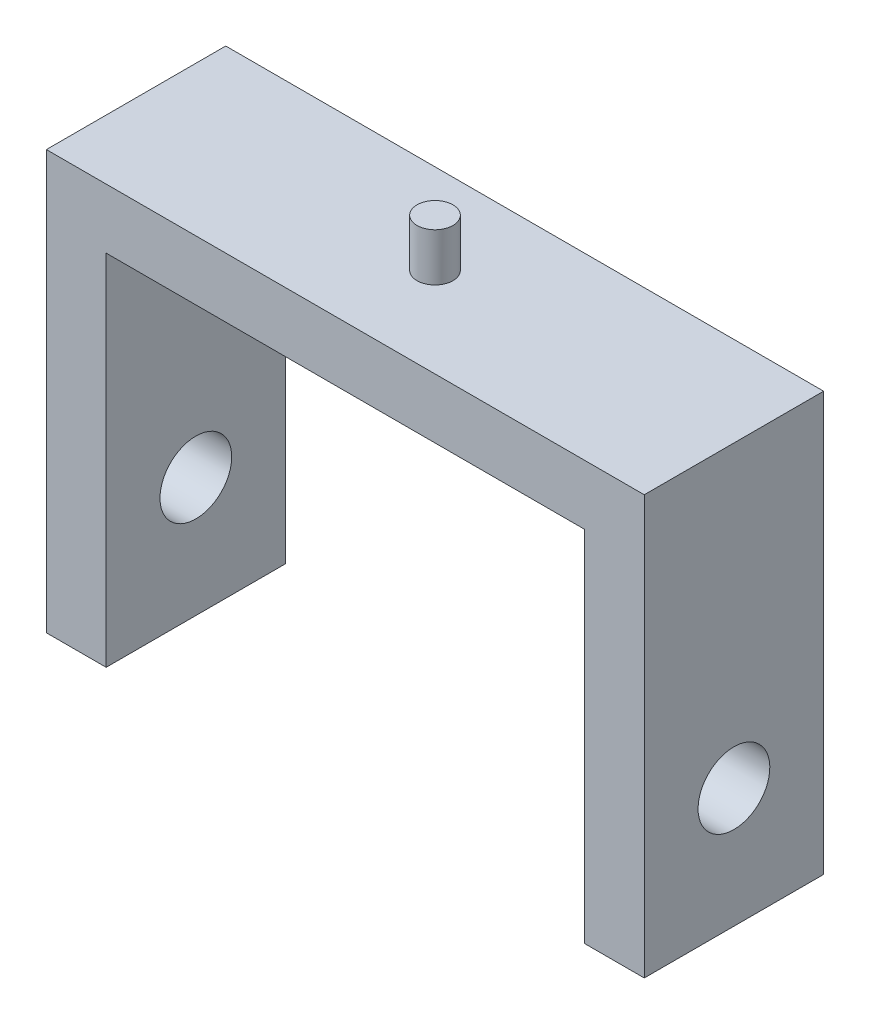
from build123d import *

# Parameters (mm, degrees)
EXTRUDE_THIN1_DEPTH     = 7.5
SKETCH2_R               = 1.5
BOSS_EXTRUDE1_DEPTH     = 4
SKETCH3_R               = 3
CUT_EXTRUDE1_DEPTH      = 1
CUT_EXTRUDE1_DEPTH_BACK = 51


with BuildPart() as part:
    # Sketch1 → Extrude-Thin1 (new body, symmetric)
    with BuildSketch(Plane.XY):
        Polygon((-20, -15), (-20, 15), (20, 15), (20, -15), (25, -15), (25, 20), (-25, 20), (-25, -15), align=None)
    extrude(amount=EXTRUDE_THIN1_DEPTH, both=True)

    # Sketch2 → Boss-Extrude1 (add)
    with BuildSketch(Plane(origin=(0, 20, 0), x_dir=(1, 0, 0), z_dir=(0, 1, 0))):
        Circle(SKETCH2_R)
    extrude(amount=BOSS_EXTRUDE1_DEPTH)

    # Sketch3 → Cut-Extrude1 (cut, two sides)
    with BuildSketch(Plane(origin=(25, 0, 0), x_dir=(0, 0, -1), z_dir=(1, 0, 0))) as cut_extrude1_sk:
        with Locations((0, -5)):
            Circle(SKETCH3_R)
    extrude(amount=CUT_EXTRUDE1_DEPTH, mode=Mode.SUBTRACT)
    extrude(cut_extrude1_sk.sketch, amount=-CUT_EXTRUDE1_DEPTH_BACK, mode=Mode.SUBTRACT)


solid = part.part
